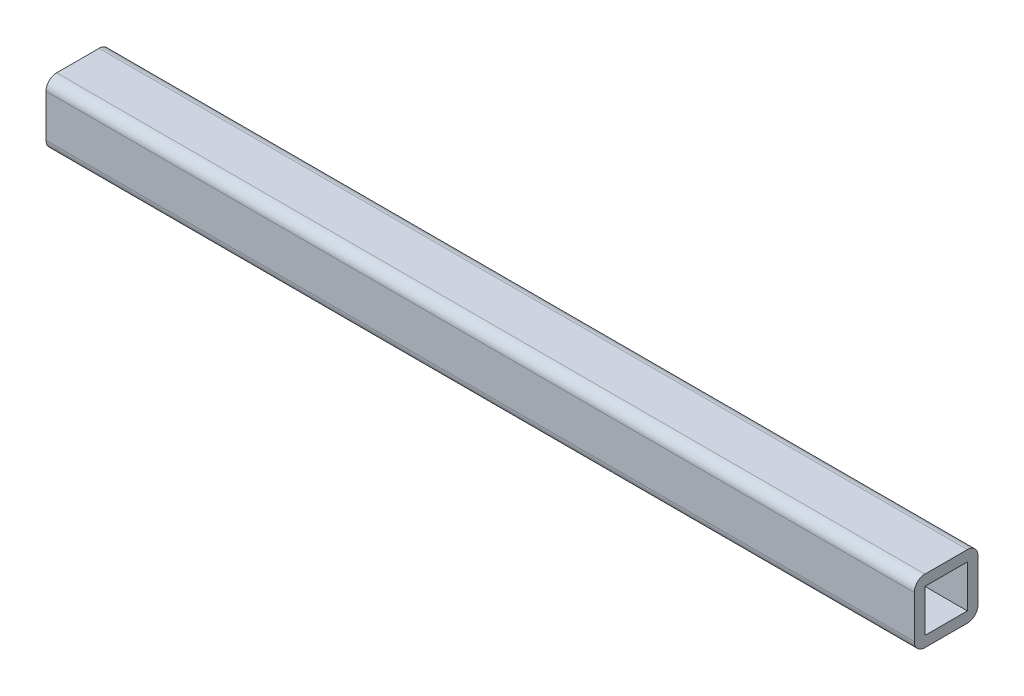
from build123d import *

# Parameters (mm, degrees)
SKETCH1_W           = 38.1
SKETCH1_H           = 38.1
SKETCH1_W_2         = 25.4
SKETCH1_H_2         = 25.4
BOSS_EXTRUDE1_DEPTH = 259.55625
FILLET1_R           = 6.35


with BuildPart() as part:
    # Sketch1 → Boss-Extrude1 (new body, symmetric)
    with BuildSketch(Plane(origin=(0, 0, 0), x_dir=(0, 0, -1), z_dir=(1, 0, 0))):
        Rectangle(SKETCH1_W, SKETCH1_H)
        Rectangle(SKETCH1_W_2, SKETCH1_H_2, mode=Mode.SUBTRACT)
    extrude(amount=BOSS_EXTRUDE1_DEPTH, both=True)

    # Fillet1
    fillet1_edges = [part.edges().sort_by_distance(p)[0] for p in [
        (0, -19.05, -19.05),
        (0, -19.05, 19.05),
        (0, 19.05, 19.05),
        (0, 19.05, -19.05),
    ]]
    fillet(fillet1_edges, radius=FILLET1_R)


solid = part.part
